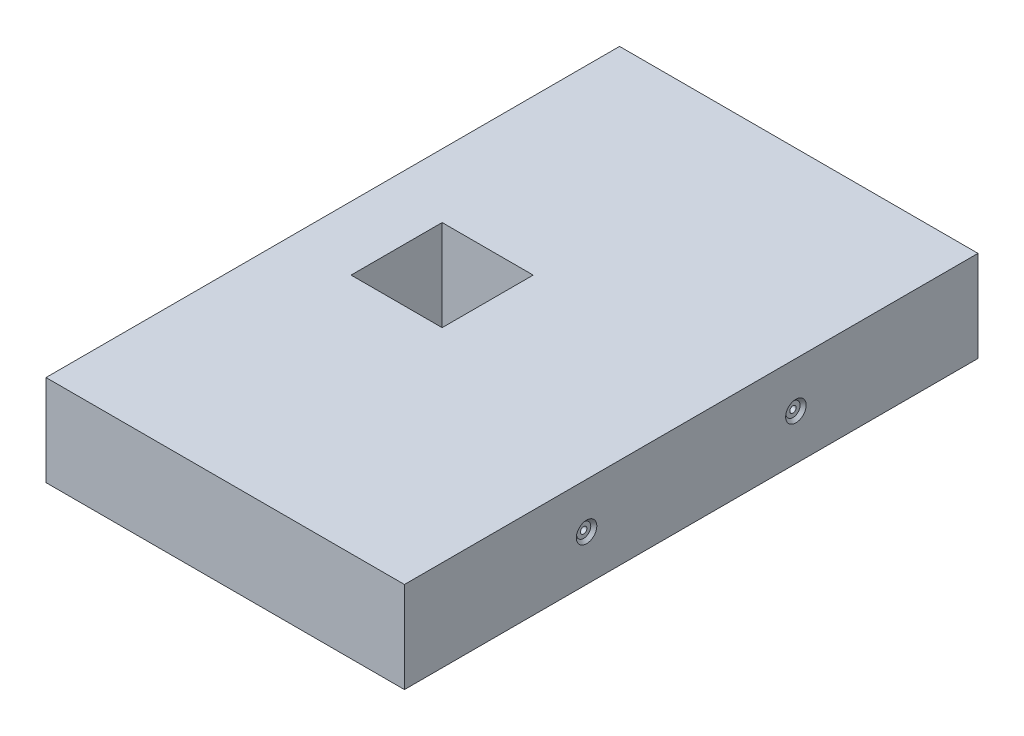
from build123d import *

# Parameters (mm, degrees)
SKETCH1_W                                   = 100
SKETCH1_H                                   = 160
SKETCH1_W_2                                 = 25.4
SKETCH1_H_2                                 = 25.4
BOSS_EXTRUDE1_DEPTH                         = 25.4
CBORE_FOR_0_BINDING_HEAD_MACHINE_SC_2_COUNT = 2
CBORE_FOR_0_BINDING_HEAD_MACHINE_SC_2_PITCH = 58.4


with BuildPart() as part:
    # Sketch1 → Boss-Extrude1 (new body)
    with BuildSketch(Plane(origin=(0, 0, 0), x_dir=(1, 0, 0), z_dir=(0, 1, 0))):
        Rectangle(SKETCH1_W, SKETCH1_H)
        with Locations((-19.49, 0)):
            Rectangle(SKETCH1_W_2, SKETCH1_H_2, mode=Mode.SUBTRACT)
    extrude(amount=BOSS_EXTRUDE1_DEPTH)

    # Sketch3 → CBORE for #0 Binding Head Machine Screw1 (revolve, cut)
    with BuildSketch(Plane(origin=(50, 12.7, 29.2), x_dir=(0, 0, -1), z_dir=(0, 1, 0))):
        Polygon((0, 0), (0, 30.53416509), (0.889, 30), (0.889, 0.8128), (1.98501, 0.8128), (1.98501, 0.87249), (2.8575, 0), align=None)
    cbore_for_0_binding_head_machine_screw1 = revolve(axis=Axis((56.35, 12.7, 29.2), (-1, 0, 0)), mode=Mode.SUBTRACT)

    # CBORE for _0 Binding Head Machine Sc 2: CBORE for #0 Binding Head Machine Screw1 ×2
    with Locations(*[(0, 0, -i * CBORE_FOR_0_BINDING_HEAD_MACHINE_SC_2_PITCH) for i in range(1, CBORE_FOR_0_BINDING_HEAD_MACHINE_SC_2_COUNT)]):
        add(cbore_for_0_binding_head_machine_screw1, mode=Mode.SUBTRACT)


solid = part.part
